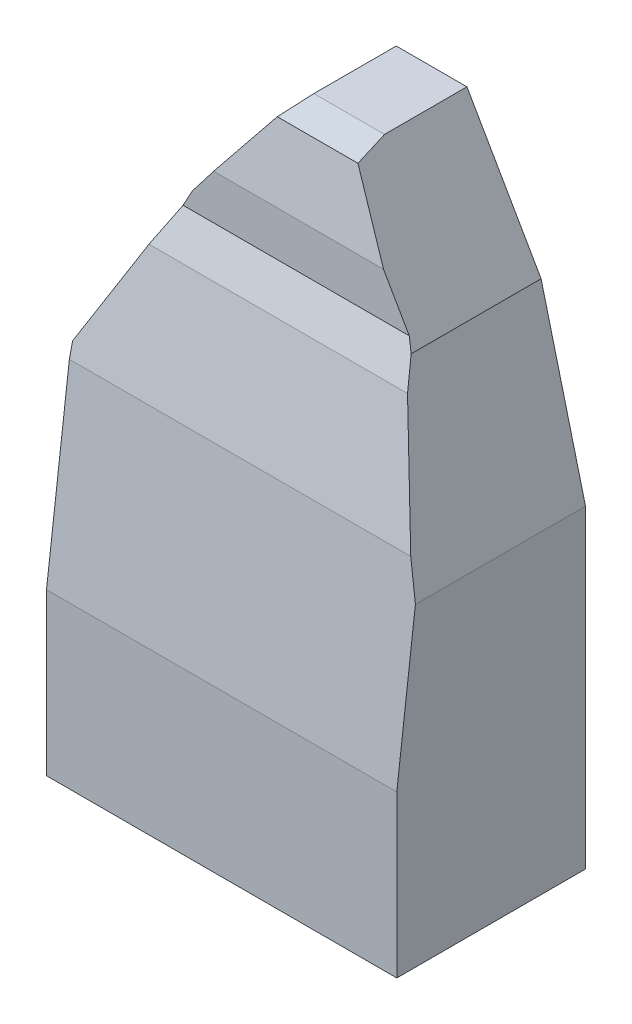
from build123d import *

# Parameters (mm, degrees)
BOSS_EXTRUDE1_DEPTH = 101.6
BOSS_EXTRUDE2_DEPTH = 431.8
CUT_EXTRUDE1_DEPTH  = 132.021743181
CUT_EXTRUDE2_DEPTH  = 132.021743181


with BuildPart() as part:
    # Sketch1 → Boss-Extrude1 (new body)
    with BuildSketch(Plane.XY):
        Polygon((0, 0), (431.8, 0), (431.8, 387.403361345), (377.065490396, 602.774956458), (285.641844577, 762), (198.504201681, 762), (102.453781513, 637.134453782), (0, 448.235294118), align=None)
    extrude(amount=BOSS_EXTRUDE1_DEPTH)

    # Sketch2 → Boss-Extrude2 (add)
    with BuildSketch(Plane.ZY):
        Polygon((101.6, 0), (232.621743181, 0), (232.621743181, 198.64821401), (204.451845393, 430.506603568), (172.780455352, 570.81191653), (155.089264466, 615.704741573), (155.089264466, 670.908278379), (139.607943989, 752.787376516), (101.6, 762), align=None)
    extrude(amount=-BOSS_EXTRUDE2_DEPTH)

    # Sketch3 → Cut-Extrude1 (cut, through all)
    with BuildSketch(Plane(origin=(0, 0, 101.6), x_dir=(-1, 0, 0), z_dir=(0, 0, -1))):
        Polygon((0, 448.235294118), (-102.079559314, 636.444481603), (-205.052343037, 770.512583763), (-205.052343037, 987.342816442), (227.879484492, 941.92173413), (179.71587047, 482.849418415), align=None)
    extrude(amount=-CUT_EXTRUDE1_DEPTH, mode=Mode.SUBTRACT)

    # Sketch4 → Cut-Extrude2 (cut, through all)
    with BuildSketch(Plane(origin=(0, 0, 101.6), x_dir=(-1, 0, 0), z_dir=(0, 0, -1))):
        Polygon((-431.8, 387.403361345), (-377.065490396, 602.774956458), (-285.641844577, 762), (-386.647779508, 961.526140846), (-935.090979015, 961.526140846), (-884.913915701, 472.949119069), align=None)
    extrude(amount=-CUT_EXTRUDE2_DEPTH, mode=Mode.SUBTRACT)


solid = part.part
